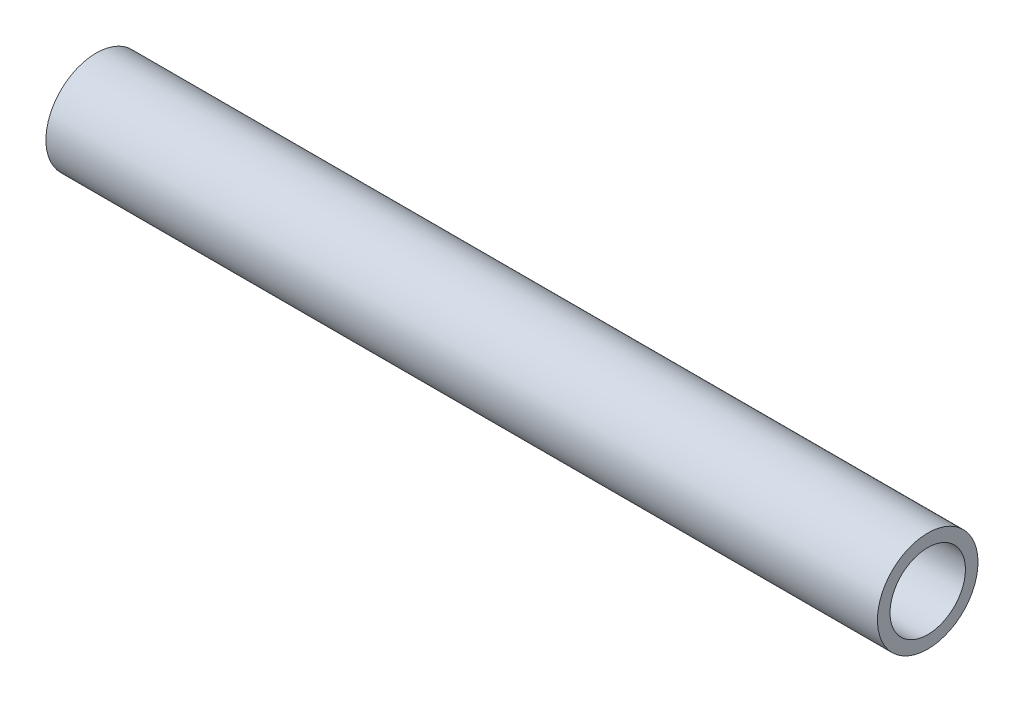
from build123d import *

# Parameters (mm, degrees)
SKETCH1_R           = 12.7
SKETCH1_R_2         = 9.525
BOSS_EXTRUDE1_DEPTH = 105


with BuildPart() as part:
    # Sketch1 → Boss-Extrude1 (new body, symmetric)
    with BuildSketch(Plane(origin=(0, 0, 0), x_dir=(0, 0, -1), z_dir=(1, 0, 0))):
        Circle(SKETCH1_R)
        Circle(SKETCH1_R_2, mode=Mode.SUBTRACT)
    extrude(amount=BOSS_EXTRUDE1_DEPTH, both=True)


solid = part.part
